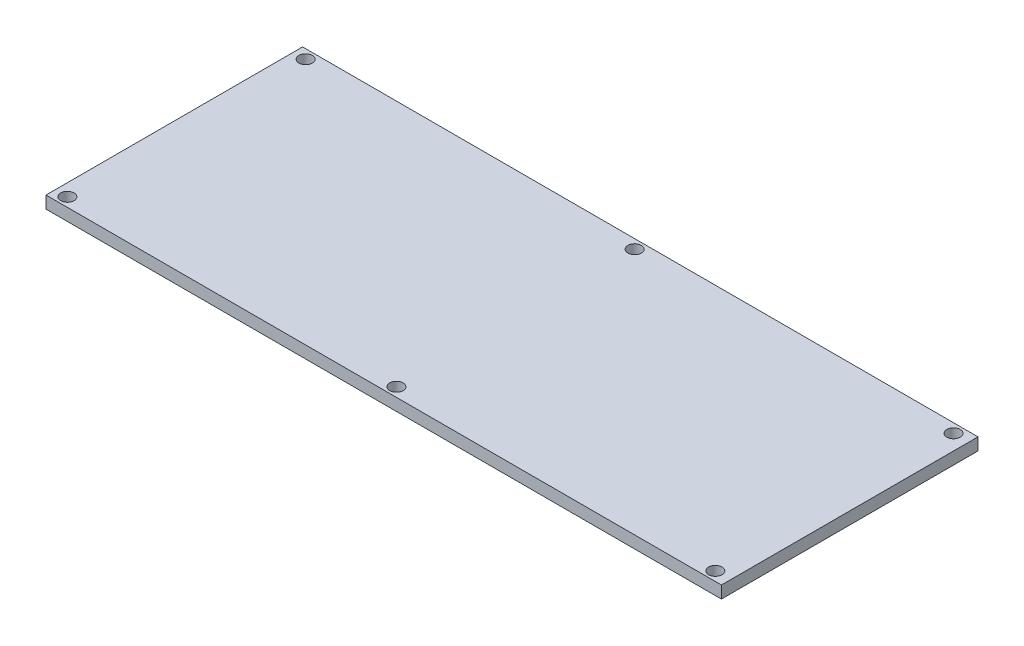
from build123d import *

# Parameters (mm, degrees)
SKETCH1_W                      = 110.56
SKETCH1_H                      = 42
BOSS_EXTRUDE1_DEPTH            = 2
F_2_2_2_2_DIAMETER_HOLE1_D     = 2.2
F_2_2_2_2_DIAMETER_HOLE1_DEPTH = 2


with BuildPart() as part:
    # Sketch1 → Boss-Extrude1 (new body)
    with BuildSketch(Plane(origin=(0, 0, 0), x_dir=(1, 0, 0), z_dir=(0, 1, 0))):
        Rectangle(SKETCH1_W, SKETCH1_H)
    extrude(amount=BOSS_EXTRUDE1_DEPTH)

    # Ø2.2 (2.2) Diameter Hole1
    with Locations(Plane(origin=(0, 0, 0), x_dir=(-1, 0, 0), z_dir=(0, -1, 0))):
        with Locations((53.28, -19.5), (53.28, 19.5), (-52.78, 19.5), (-0.579521869, 19.5), (-0.579521869, -19.5), (-52.78, -19.5)):
            Hole(F_2_2_2_2_DIAMETER_HOLE1_D / 2, depth=F_2_2_2_2_DIAMETER_HOLE1_DEPTH)


solid = part.part
